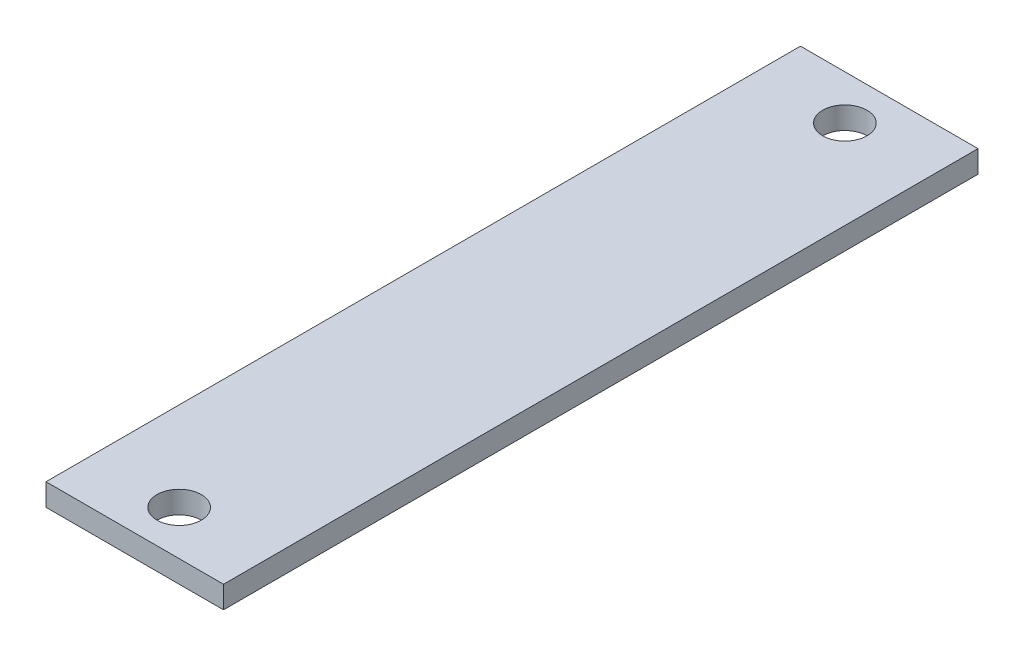
from build123d import *

# Parameters (mm, degrees)
SKETCH1_W           = 25.4
SKETCH1_H           = 107.95
SKETCH1_R           = 3.175
BOSS_EXTRUDE1_DEPTH = 3.175


with BuildPart() as part:
    # Sketch1 → Boss-Extrude1 (new body)
    with BuildSketch(Plane.XZ.offset(3.175)):
        with Locations((-0.642134808, -2.283393272)):
            Rectangle(SKETCH1_W, SKETCH1_H)
        with Locations((-0.642134808, -49.908393272)):
            Circle(SKETCH1_R, mode=Mode.SUBTRACT)
        with Locations((-0.642134808, 45.341606728)):
            Circle(SKETCH1_R, mode=Mode.SUBTRACT)
    extrude(amount=-BOSS_EXTRUDE1_DEPTH)


solid = part.part
